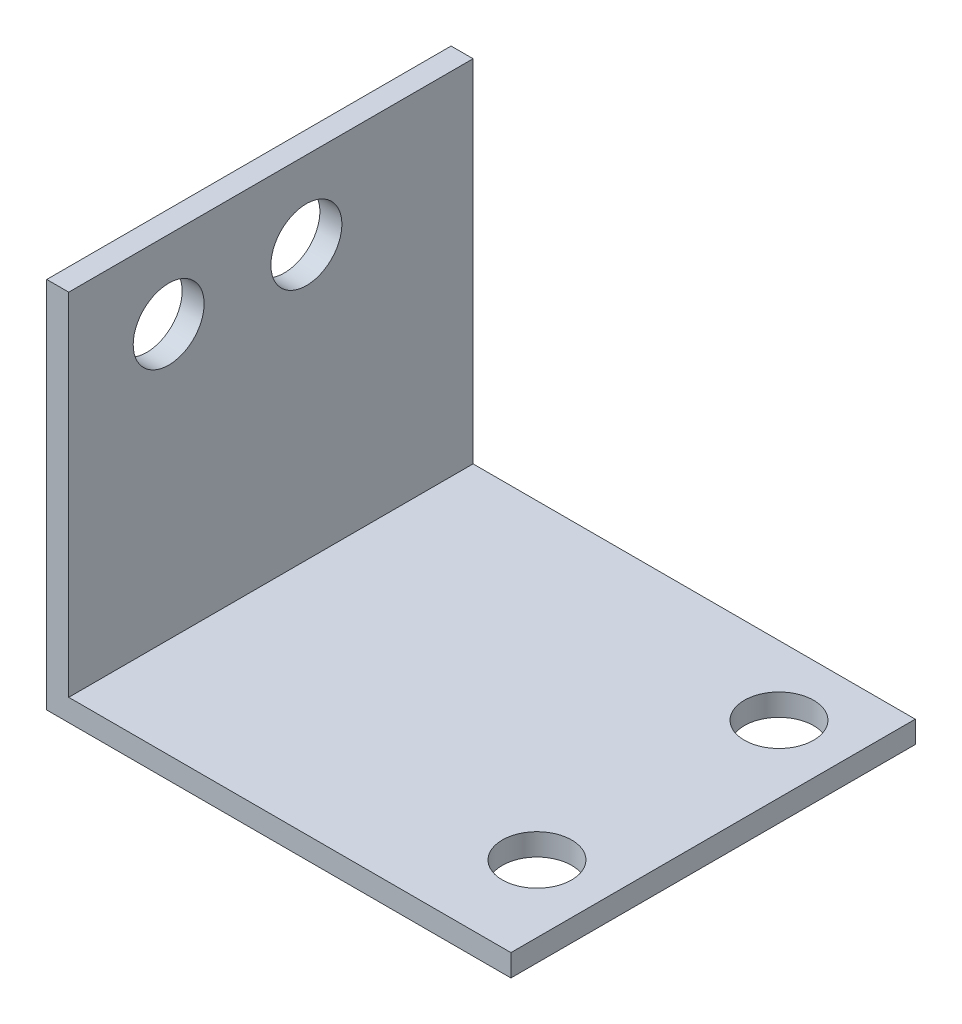
from build123d import *

# Parameters (mm, degrees)
SKETCH1_W  = 42.2
SKETCH1_H  = 36.76
SKETCH1_R  = 3.15
BASE_DEPTH = 2
SKETCH3_W  = 36.76
SKETCH3_H  = 33.9
SKETCH3_R  = 3.225
TAB_DEPTH  = 2


with BuildPart() as part:
    # Sketch1 → Base (new body)
    with BuildSketch(Plane(origin=(0, 0, 0), x_dir=(1, 0, 0), z_dir=(0, 1, 0))):
        Rectangle(SKETCH1_W, SKETCH1_H)
        with Locations((14.99, 12.1)):
            Circle(SKETCH1_R, mode=Mode.SUBTRACT)
        with Locations((14.99, -9.9)):
            Circle(SKETCH1_R, mode=Mode.SUBTRACT)
    extrude(amount=BASE_DEPTH)

    # Sketch3 → Tab (add)
    with BuildSketch(Plane.ZY.offset(21.1)):
        with Locations((0, 16.95)):
            Rectangle(SKETCH3_W, SKETCH3_H)
        with Locations((-3.225, 26.835)):
            Circle(SKETCH3_R, mode=Mode.SUBTRACT)
        with Locations((9.295, 26.835)):
            Circle(SKETCH3_R, mode=Mode.SUBTRACT)
    extrude(amount=-TAB_DEPTH)


solid = part.part
